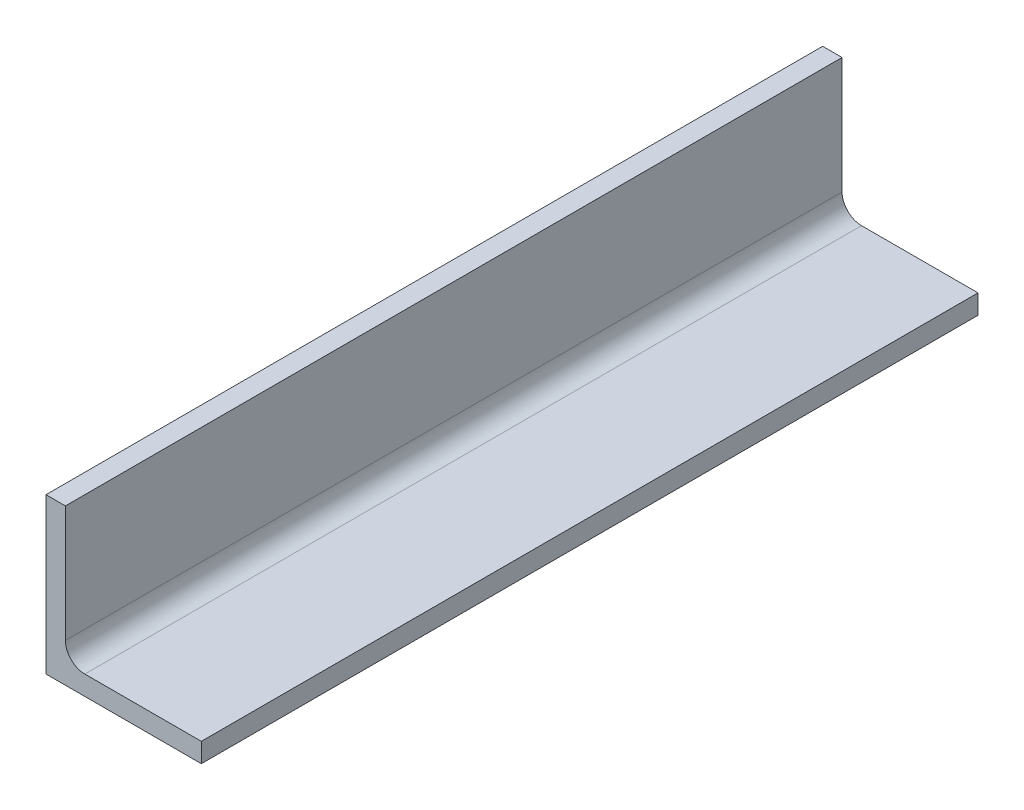
from build123d import *

# Parameters (mm, degrees)
BOSS_EXTRUDE1_DEPTH = 127


with BuildPart() as part:
    # Sketch2 → Boss-Extrude1 (new body, symmetric)
    with BuildSketch(Plane.XY):
        with BuildLine():
            Line((0, 0), (0, 50.8))
            Line((0, 50.8), (6.35, 50.8))
            Line((6.35, 50.8), (6.35, 12.7))
            ThreePointArc((6.35, 12.7), (8.209871939, 8.209871939), (12.7, 6.35))
            Line((12.7, 6.35), (50.8, 6.35))
            Line((50.8, 6.35), (50.8, 0))
            Line((50.8, 0), (0, 0))
        make_face()
    extrude(amount=BOSS_EXTRUDE1_DEPTH, both=True)


solid = part.part
